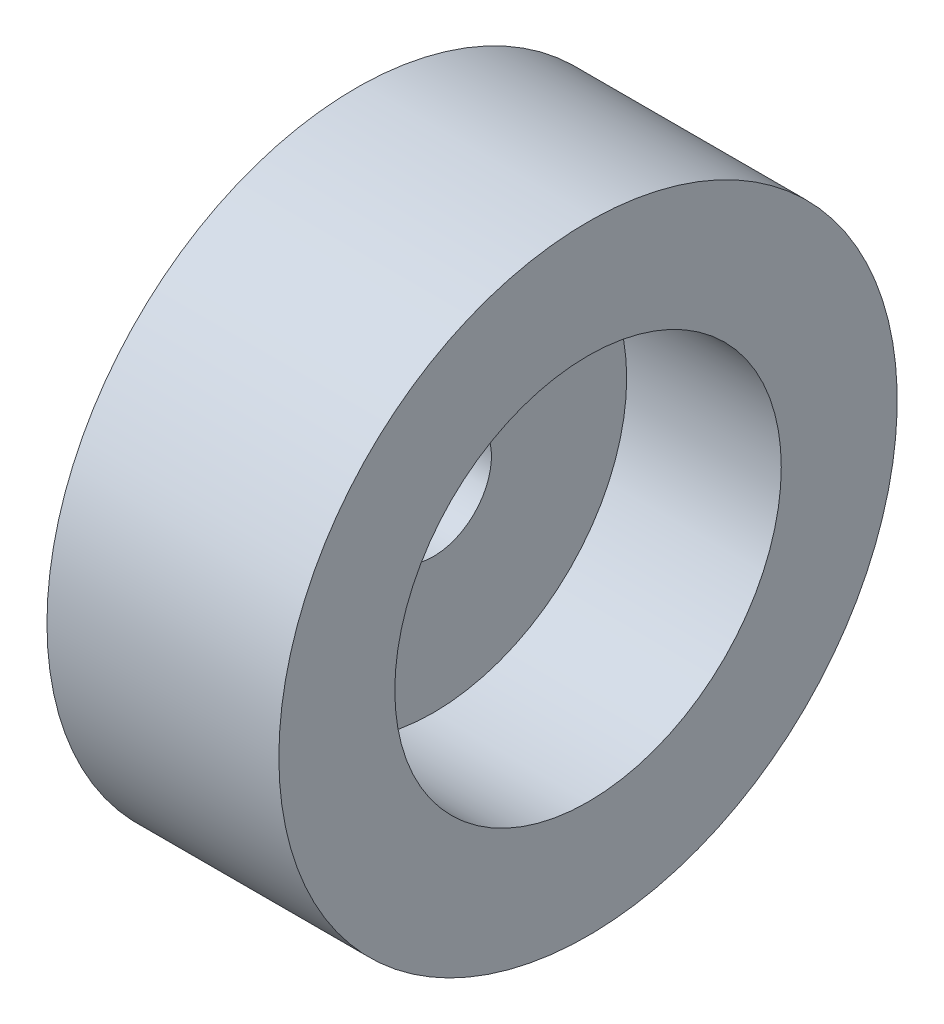
from build123d import *


with BuildPart() as part:
    # Sketch1 → Revolve1 (revolve)
    with BuildSketch(Plane.XY):
        Polygon((0, 0.75), (2, 0.75), (2, 2.5), (4, 2.5), (4, 4), (1, 4), (1, 2.5), (0, 2.5), align=None)
    revolve(axis=Axis((0, 0, 0), (1, 0, 0)))


solid = part.part
